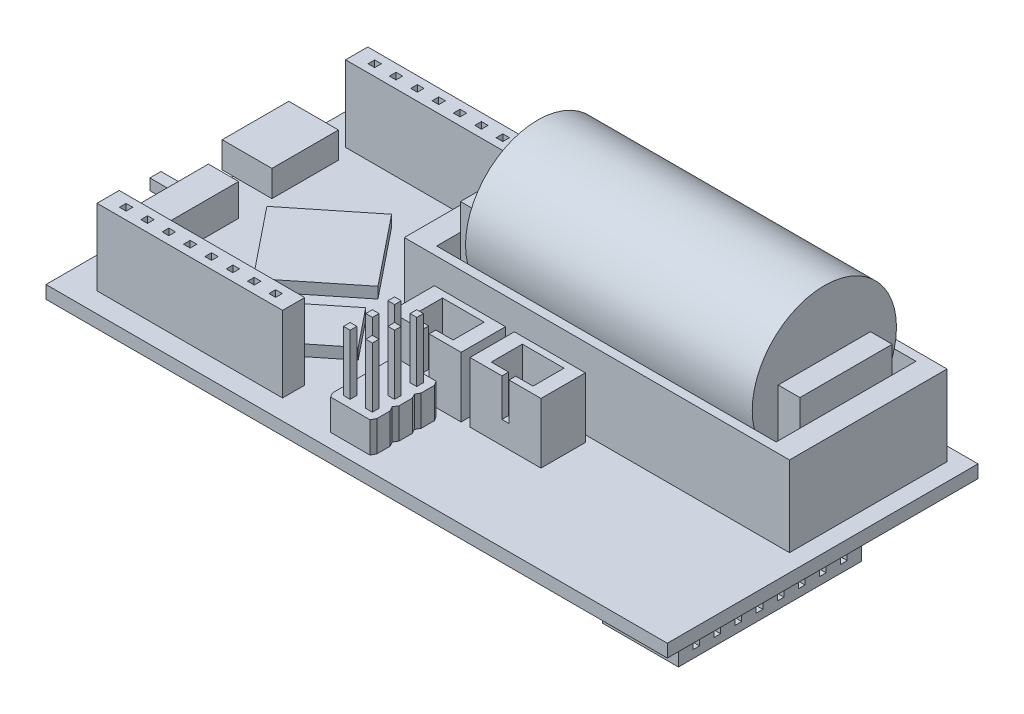
from build123d import *

# Parameters (mm, degrees)
SKETCH1_W            = 70
SKETCH1_H            = 35
BOSS_EXTRUDE1_DEPTH  = 1.45
SKETCH2_W            = 3.4
SKETCH2_H            = 11.8
BOSS_EXTRUDE2_DEPTH  = 3.6
SKETCH3_W            = 5.6
SKETCH3_H            = 7.5
BOSS_EXTRUDE3_DEPTH  = 2.95
SKETCH4_W            = 5.5
SKETCH4_H            = 1.25
CUT_EXTRUDE1_DEPTH   = 2
SKETCH5_W            = 1.25
SKETCH5_H            = 1.25
BOSS_EXTRUDE4_DEPTH  = 4.2
SKETCH11_W           = 20.9
SKETCH11_H           = 2.5
BOSS_EXTRUDE5_DEPTH  = 8.55
BOSS_EXTRUDE6_DEPTH  = 1.25
BOSS_EXTRUDE7_DEPTH  = 1.25
SKETCH14_W           = 43.4
SKETCH14_H           = 17.75
BOSS_EXTRUDE8_DEPTH  = 9.05
SKETCH15_W           = 38.25
SKETCH15_H           = 15.75
CUT_EXTRUDE3_DEPTH   = 9.05
SKETCH16_W           = 10.4
SKETCH16_H           = 12.05
BOSS_EXTRUDE9_DEPTH  = 3.5
SKETCH17_W           = 10.4
SKETCH17_H           = 12.05
BOSS_EXTRUDE10_DEPTH = 2.6
SKETCH18_R           = 8.125
BOSS_EXTRUDE11_DEPTH = 32.3
SKETCH19_W           = 8
SKETCH19_H           = 5
BOSS_EXTRUDE12_DEPTH = 6.8
SKETCH20_W           = 4.7
SKETCH20_H           = 3.5
CUT_EXTRUDE4_DEPTH   = 6.8
SKETCH21_W           = 0.8
SKETCH21_H           = 0.75
CUT_EXTRUDE5_DEPTH   = 4.25
SKETCH23_W           = 3
SKETCH23_H           = 7.5
BOSS_EXTRUDE13_DEPTH = 3.45
BOSS_EXTRUDE17_DEPTH = 3.45
BOSS_EXTRUDE18_DEPTH = 3.45
BOSS_EXTRUDE19_DEPTH = 3.45
SKETCH32_W           = 8.55
SKETCH32_H           = 20.65
BOSS_EXTRUDE23_DEPTH = 2.5
SKETCH33_W           = 13.4
SKETCH33_H           = 19
BOSS_EXTRUDE24_DEPTH = 0.875
SKETCH34_W           = 5.2
SKETCH34_H           = 5.2
BOSS_EXTRUDE25_DEPTH = 0.875
SKETCH35_W           = 0.75
SKETCH35_H           = 0.75
CUT_EXTRUDE6_DEPTH   = 6.75
SKETCH36_W           = 0.75
SKETCH36_H           = 0.75
CUT_EXTRUDE7_DEPTH   = 6.75
SKETCH37_W           = 0.75
SKETCH37_H           = 0.75
CUT_EXTRUDE8_DEPTH   = 6.75
SKETCH38_W           = 6.613602653
SKETCH38_H           = 2.154994123
CUT_EXTRUDE9_DEPTH   = 5
SKETCH39_W           = 0.75
SKETCH39_H           = 0.75
BOSS_EXTRUDE26_DEPTH = 6.75


with BuildPart() as part:
    # Sketch1 → Boss-Extrude1 (new body)
    with BuildSketch(Plane(origin=(0, 0, 0), x_dir=(1, 0, 0), z_dir=(0, 1, 0))):
        Rectangle(SKETCH1_W, SKETCH1_H)
    extrude(amount=BOSS_EXTRUDE1_DEPTH)

    # Sketch2 → Boss-Extrude2 (add)
    with BuildSketch(Plane(origin=(0, 1.45, 0), x_dir=(1, 0, 0), z_dir=(0, 1, 0))):
        with Locations((-32.3, -6.1)):
            Rectangle(SKETCH2_W, SKETCH2_H)
    extrude(amount=BOSS_EXTRUDE2_DEPTH)

    # Sketch3 → Boss-Extrude3 (add)
    with BuildSketch(Plane(origin=(0, 1.45, 0), x_dir=(1, 0, 0), z_dir=(0, 1, 0))):
        with Locations((-33.45, 7.35)):
            Rectangle(SKETCH3_W, SKETCH3_H)
    extrude(amount=BOSS_EXTRUDE3_DEPTH)

    # Sketch4 → Cut-Extrude1 (cut)
    with BuildSketch(Plane.ZY.offset(34)):
        with Locations((6.1, 4.175)):
            Rectangle(SKETCH4_W, SKETCH4_H)
    extrude(amount=-CUT_EXTRUDE1_DEPTH, mode=Mode.SUBTRACT)

    # Sketch5 → Boss-Extrude4 (add)
    with BuildSketch(Plane.ZY.offset(32)):
        with Locations((3.975, 4.175)):
            Rectangle(SKETCH5_W, SKETCH5_H)
    extrude(amount=BOSS_EXTRUDE4_DEPTH)

    # Sketch11 → Boss-Extrude5 (add)
    with BuildSketch(Plane(origin=(0, 1.45, 0), x_dir=(1, 0, 0), z_dir=(0, 1, 0))):
        with Locations((-21.05, 14)):
            Rectangle(SKETCH11_W, SKETCH11_H)
        with Locations((-21.05, -14)):
            Rectangle(SKETCH11_W, SKETCH11_H)
    extrude(amount=BOSS_EXTRUDE5_DEPTH)

    # Sketch12 → Boss-Extrude6 (add)
    with BuildSketch(Plane(origin=(0, 1.45, 0), x_dir=(1, 0, 0), z_dir=(0, 1, 0))):
        Polygon((-28.934765062, 1.314868413), (-21.135479697, 7.5735542), (-14.876793909, -0.225731165), (-22.676079275, -6.484416953), align=None)
    extrude(amount=BOSS_EXTRUDE6_DEPTH)

    # Sketch13 → Boss-Extrude7 (add)
    with BuildSketch(Plane(origin=(0, 1.45, 0), x_dir=(1, 0, 0), z_dir=(0, 1, 0))):
        Polygon((-19.129279476, -7.544810037), (-13.474797586, -3.007262841), (-10.032520403, -7.296869792), (-15.687002293, -11.834416988), align=None)
    extrude(amount=BOSS_EXTRUDE7_DEPTH)

    # Sketch14 → Boss-Extrude8 (add)
    with BuildSketch(Plane(origin=(0, 1.45, 0), x_dir=(1, 0, 0), z_dir=(0, 1, 0))):
        with Locations((11.35, 7.089637677)):
            Rectangle(SKETCH14_W, SKETCH14_H)
    extrude(amount=BOSS_EXTRUDE8_DEPTH)

    # Sketch15 → Cut-Extrude3 (cut)
    with BuildSketch(Plane(origin=(0, 10.5, 0), x_dir=(1, 0, 0), z_dir=(0, 1, 0))):
        with Locations((11.425, 7.089637677)):
            Rectangle(SKETCH15_W, SKETCH15_H)
    extrude(amount=-CUT_EXTRUDE3_DEPTH, mode=Mode.SUBTRACT)

    # Sketch16 → Boss-Extrude9 (add)
    with BuildSketch(Plane(origin=(-7.7, 0, 0), x_dir=(0, 0, -1), z_dir=(1, 0, 0))):
        with Locations((7.089637677, 7.475)):
            Rectangle(SKETCH16_W, SKETCH16_H)
    extrude(amount=BOSS_EXTRUDE9_DEPTH)

    # Sketch17 → Boss-Extrude10 (add)
    with BuildSketch(Plane.ZY.offset(-30.55)):
        with Locations((-7.084637677, 7.475)):
            Rectangle(SKETCH17_W, SKETCH17_H)
    extrude(amount=BOSS_EXTRUDE10_DEPTH)

    # Sketch18 → Boss-Extrude11 (add)
    with BuildSketch(Plane(origin=(-4.2, 0, 0), x_dir=(0, 0, -1), z_dir=(1, 0, 0))):
        with Locations((7.089637677, 12.474842125)):
            Circle(SKETCH18_R)
    extrude(amount=BOSS_EXTRUDE11_DEPTH)

    # Sketch19 → Boss-Extrude12 (add)
    with BuildSketch(Plane(origin=(0, 1.45, 0), x_dir=(1, 0, 0), z_dir=(0, 1, 0))):
        with Locations((6.8, -5.035362323)):
            Rectangle(SKETCH19_W, SKETCH19_H)
        with Locations((-2.2, -5.035362323)):
            Rectangle(SKETCH19_W, SKETCH19_H)
    extrude(amount=BOSS_EXTRUDE12_DEPTH)

    # Sketch20 → Cut-Extrude4 (cut)
    with BuildSketch(Plane(origin=(0, 8.25, 0), x_dir=(1, 0, 0), z_dir=(0, 1, 0))):
        with Locations((-2.2, -5.035362323)):
            Rectangle(SKETCH20_W, SKETCH20_H)
        with Locations((6.8, -5.035362323)):
            Rectangle(SKETCH20_W, SKETCH20_H)
    extrude(amount=-CUT_EXTRUDE4_DEPTH, mode=Mode.SUBTRACT)

    # Sketch21 → Cut-Extrude5 (cut)
    with BuildSketch(Plane(origin=(0, 8.25, 0), x_dir=(1, 0, 0), z_dir=(0, 1, 0))):
        with Locations((-2.2, -7.160362323)):
            Rectangle(SKETCH21_W, SKETCH21_H)
        with Locations((6.8, -7.160362323)):
            Rectangle(SKETCH21_W, SKETCH21_H)
    extrude(amount=-CUT_EXTRUDE5_DEPTH, mode=Mode.SUBTRACT)

    # Sketch23 → Boss-Extrude13 (add)
    with BuildSketch(Plane(origin=(0, 1.45, 0), x_dir=(1, 0, 0), z_dir=(0, 1, 0))):
        with Locations((-2.332801009, -12.15)):
            Rectangle(SKETCH23_W, SKETCH23_H)
    extrude(amount=BOSS_EXTRUDE13_DEPTH)

    # Sketch26 → Boss-Extrude17 (add)
    with BuildSketch(Plane(origin=(0, 1.45, 0), x_dir=(1, 0, 0), z_dir=(0, 1, 0))):
        Polygon((-0.832801009, -8.4), (-0.145479272, -8.4), (0.167198991, -8.9), (0.167198991, -10.4), (-0.100494835, -10.9), (-0.832801009, -10.9), align=None)
        Polygon((-3.832801009, -8.4), (-3.832801009, -10.9), (-4.52957998, -10.9), (-4.832801009, -10.4), (-4.832801009, -8.9), (-4.52957998, -8.4), align=None)
    extrude(amount=BOSS_EXTRUDE17_DEPTH)

    # Sketch27 → Boss-Extrude18 (add)
    with BuildSketch(Plane(origin=(0, 1.45, 0), x_dir=(1, 0, 0), z_dir=(0, 1, 0))):
        Polygon((-3.832801009, -10.9), (-4.52957998, -10.9), (-4.832801009, -11.4), (-4.832801009, -12.9), (-4.52957998, -13.4), (-3.832801009, -13.4), align=None)
        Polygon((-0.832801009, -10.9), (-0.100494835, -10.9), (0.167198991, -11.4), (0.167198991, -12.9), (-0.126891499, -13.384944087), (-0.832801009, -13.384944087), align=None)
    extrude(amount=BOSS_EXTRUDE18_DEPTH)

    # Sketch28 → Boss-Extrude19 (add)
    with BuildSketch(Plane(origin=(0, 1.45, 0), x_dir=(1, 0, 0), z_dir=(0, 1, 0))):
        Polygon((-3.832801009, -13.4), (-4.52957998, -13.4), (-4.832801009, -13.9), (-4.832801009, -15.4), (-4.52957998, -15.9), (-3.832801009, -15.9), align=None)
        Polygon((-0.832801009, -13.384944087), (-0.126891499, -13.384944087), (0.167198991, -13.884944087), (0.167198991, -15.384944087), (-0.099646701, -15.9), (-0.832801009, -15.9), align=None)
    extrude(amount=BOSS_EXTRUDE19_DEPTH)

    # Sketch32 → Boss-Extrude23 (add)
    with BuildSketch(Plane.XZ):
        with Locations((29.725, 4.925)):
            Rectangle(SKETCH32_W, SKETCH32_H)
    extrude(amount=BOSS_EXTRUDE23_DEPTH)

    # Sketch33 → Boss-Extrude24 (add)
    with BuildSketch(Plane.XZ):
        with Locations((8.3, 6.4)):
            Rectangle(SKETCH33_W, SKETCH33_H)
    extrude(amount=BOSS_EXTRUDE24_DEPTH)

    # Sketch34 → Boss-Extrude25 (add)
    with BuildSketch(Plane.XZ.offset(0.875)):
        with Locations((7.65, 0.9)):
            Rectangle(SKETCH34_W, SKETCH34_H)
    extrude(amount=BOSS_EXTRUDE25_DEPTH)

    # Sketch35 → Cut-Extrude6 (cut)
    with BuildSketch(Plane(origin=(0, 10, 0), x_dir=(1, 0, 0), z_dir=(0, 1, 0))):
        with Locations((-29.47, 14)):
            Rectangle(SKETCH35_W, SKETCH35_H)
        with Locations((-27.065, 14)):
            Rectangle(SKETCH35_W, SKETCH35_H)
        with Locations((-24.66, 14)):
            Rectangle(SKETCH35_W, SKETCH35_H)
        with Locations((-22.255, 14)):
            Rectangle(SKETCH35_W, SKETCH35_H)
        with Locations((-19.85, 14)):
            Rectangle(SKETCH35_W, SKETCH35_H)
        with Locations((-17.445, 14)):
            Rectangle(SKETCH35_W, SKETCH35_H)
        with Locations((-15.04, 14)):
            Rectangle(SKETCH35_W, SKETCH35_H)
        with Locations((-12.635, 14)):
            Rectangle(SKETCH35_W, SKETCH35_H)
    extrude(amount=-CUT_EXTRUDE6_DEPTH, mode=Mode.SUBTRACT)

    # Sketch36 → Cut-Extrude7 (cut)
    with BuildSketch(Plane(origin=(0, 10, 0), x_dir=(1, 0, 0), z_dir=(0, 1, 0))):
        with Locations((-29.47, -14)):
            Rectangle(SKETCH36_W, SKETCH36_H)
        with Locations((-27.065, -14)):
            Rectangle(SKETCH36_W, SKETCH36_H)
        with Locations((-24.66, -14)):
            Rectangle(SKETCH36_W, SKETCH36_H)
        with Locations((-22.255, -14)):
            Rectangle(SKETCH36_W, SKETCH36_H)
        with Locations((-19.85, -14)):
            Rectangle(SKETCH36_W, SKETCH36_H)
        with Locations((-17.445, -14)):
            Rectangle(SKETCH36_W, SKETCH36_H)
        with Locations((-15.04, -14)):
            Rectangle(SKETCH36_W, SKETCH36_H)
        with Locations((-12.635, -14)):
            Rectangle(SKETCH36_W, SKETCH36_H)
    extrude(amount=-CUT_EXTRUDE7_DEPTH, mode=Mode.SUBTRACT)

    # Sketch37 → Cut-Extrude8 (cut)
    with BuildSketch(Plane(origin=(34, 0, 0), x_dir=(0, 0, -1), z_dir=(1, 0, 0))):
        with Locations((-13.248, -1.25)):
            Rectangle(SKETCH37_W, SKETCH37_H)
        with Locations((-10.871, -1.25)):
            Rectangle(SKETCH37_W, SKETCH37_H)
        with Locations((-8.494, -1.25)):
            Rectangle(SKETCH37_W, SKETCH37_H)
        with Locations((-6.117, -1.25)):
            Rectangle(SKETCH37_W, SKETCH37_H)
        with Locations((-3.74, -1.25)):
            Rectangle(SKETCH37_W, SKETCH37_H)
        with Locations((-1.363, -1.25)):
            Rectangle(SKETCH37_W, SKETCH37_H)
        with Locations((1.014, -1.25)):
            Rectangle(SKETCH37_W, SKETCH37_H)
        with Locations((3.391, -1.25)):
            Rectangle(SKETCH37_W, SKETCH37_H)
    extrude(amount=-CUT_EXTRUDE8_DEPTH, mode=Mode.SUBTRACT)

    # Sketch38 → Cut-Extrude9 (cut)
    with BuildSketch(Plane.ZY.offset(36.25)):
        with Locations((-7.349339425, 2.924772293)):
            Rectangle(SKETCH38_W, SKETCH38_H)
    extrude(amount=-CUT_EXTRUDE9_DEPTH, mode=Mode.SUBTRACT)

    # Sketch39 → Boss-Extrude26 (add)
    with BuildSketch(Plane(origin=(0, 4.9, 0), x_dir=(1, 0, 0), z_dir=(0, 1, 0))):
        with Locations((-3.582801009, -9.65)):
            Rectangle(SKETCH39_W, SKETCH39_H)
        with Locations((-1.082801009, -9.65)):
            Rectangle(SKETCH39_W, SKETCH39_H)
        with Locations((-3.582801009, -12.15)):
            Rectangle(SKETCH39_W, SKETCH39_H)
        with Locations((-3.582801009, -14.65)):
            Rectangle(SKETCH39_W, SKETCH39_H)
        with Locations((-1.082801009, -12.15)):
            Rectangle(SKETCH39_W, SKETCH39_H)
        with Locations((-1.082801009, -14.65)):
            Rectangle(SKETCH39_W, SKETCH39_H)
    extrude(amount=BOSS_EXTRUDE26_DEPTH)


solid = part.part
